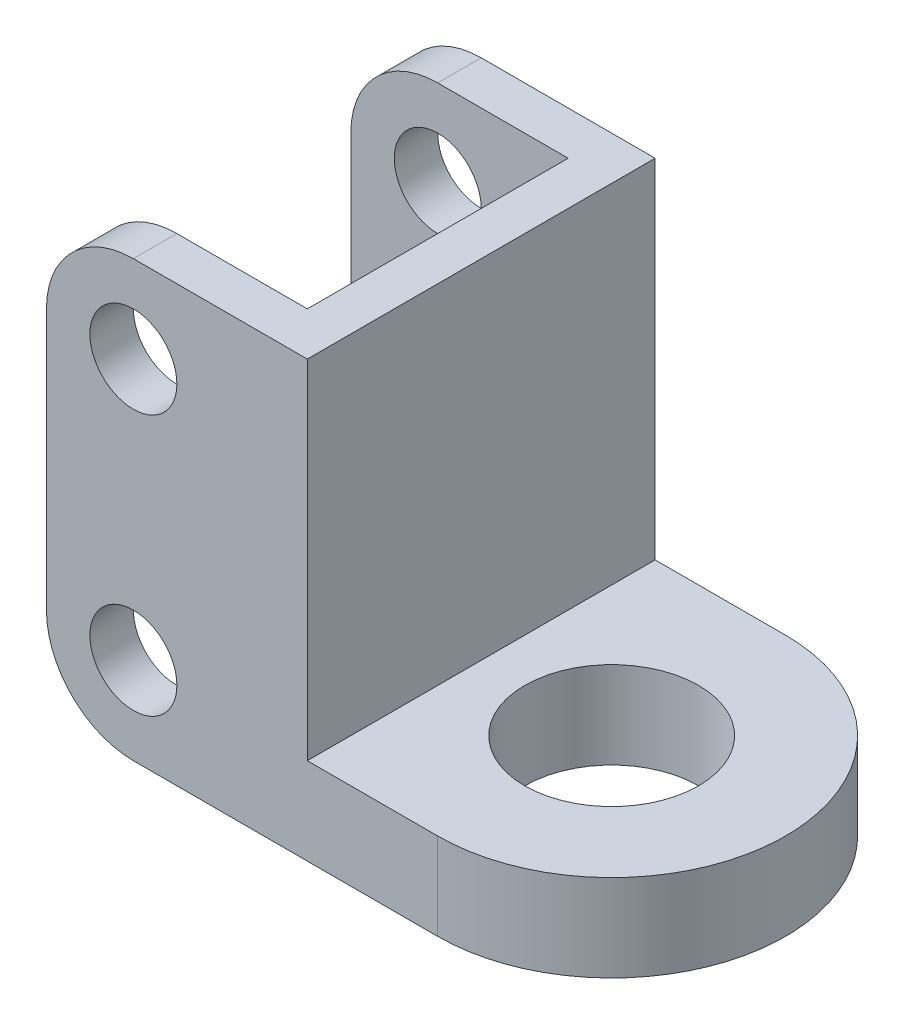
from build123d import *

# Parameters (mm, degrees)
SKETCH1_R               = 10
BOSS_EXTRUDE1_DEPTH     = 10
SKETCH2_W               = 25
SKETCH2_H               = 50
BOSS_EXTRUDE2_DEPTH     = 5
SKETCH3_W               = 25
SKETCH3_H               = 50
BOSS_EXTRUDE3_DEPTH     = 5
SKETCH4_W               = 5
SKETCH4_H               = 40
BOSS_EXTRUDE4_DEPTH     = 40
SKETCH5_R               = 5
CUT_EXTRUDE1_DEPTH      = 1
CUT_EXTRUDE1_DEPTH_BACK = 41
FILLET1_R               = 10


with BuildPart() as part:
    # Sketch1 → Boss-Extrude1 (new body)
    with BuildSketch(Plane(origin=(0, 0, 0), x_dir=(1, 0, 0), z_dir=(0, 1, 0))):
        with BuildLine():
            Line((-22.5, 15), (2.5, 15))
            Line((2.5, 15), (2.5, -15))
            Line((2.5, -15), (-22.5, -15))
            Line((-22.5, -15), (-22.5, -20))
            Line((-22.5, -20), (22.5, -20))
            ThreePointArc((22.5, -20), (42.5, 0), (22.5, 20))
            Line((22.5, 20), (-22.5, 20))
            Line((-22.5, 20), (-22.5, 15))
        make_face()
        with Locations((22.5, 0)):
            Circle(SKETCH1_R, mode=Mode.SUBTRACT)
    extrude(amount=BOSS_EXTRUDE1_DEPTH)

    # Sketch2 → Boss-Extrude2 (add)
    with BuildSketch(Plane(origin=(0, 0, -20), x_dir=(-1, 0, 0), z_dir=(0, 0, -1))):
        with Locations((10, 25)):
            Rectangle(SKETCH2_W, SKETCH2_H)
    extrude(amount=-BOSS_EXTRUDE2_DEPTH)

    # Sketch3 → Boss-Extrude3 (add)
    with BuildSketch(Plane.XY.offset(20)):
        with Locations((-10, 25)):
            Rectangle(SKETCH3_W, SKETCH3_H)
    extrude(amount=-BOSS_EXTRUDE3_DEPTH)

    # Sketch4 → Boss-Extrude4 (add)
    with BuildSketch(Plane.XY.offset(20)):
        with Locations((5, 30)):
            Rectangle(SKETCH4_W, SKETCH4_H)
    extrude(amount=-BOSS_EXTRUDE4_DEPTH)

    # Sketch5 → Cut-Extrude1 (cut, two sides)
    with BuildSketch(Plane.XY.offset(20)) as cut_extrude1_sk:
        with Locations((-12.5, 40)):
            Circle(SKETCH5_R)
        with Locations((-12.5, 10)):
            Circle(SKETCH5_R)
    extrude(amount=CUT_EXTRUDE1_DEPTH, mode=Mode.SUBTRACT)
    extrude(cut_extrude1_sk.sketch, amount=-CUT_EXTRUDE1_DEPTH_BACK, mode=Mode.SUBTRACT)

    # Fillet1
    fillet1_edges = [part.edges().sort_by_distance(p)[0] for p in [
        (-22.5, 0, -17.5),
        (-22.5, 50, -17.5),
        (-22.5, 50, 17.5),
        (-22.5, 0, 17.5),
    ]]
    fillet(fillet1_edges, radius=FILLET1_R)


solid = part.part
